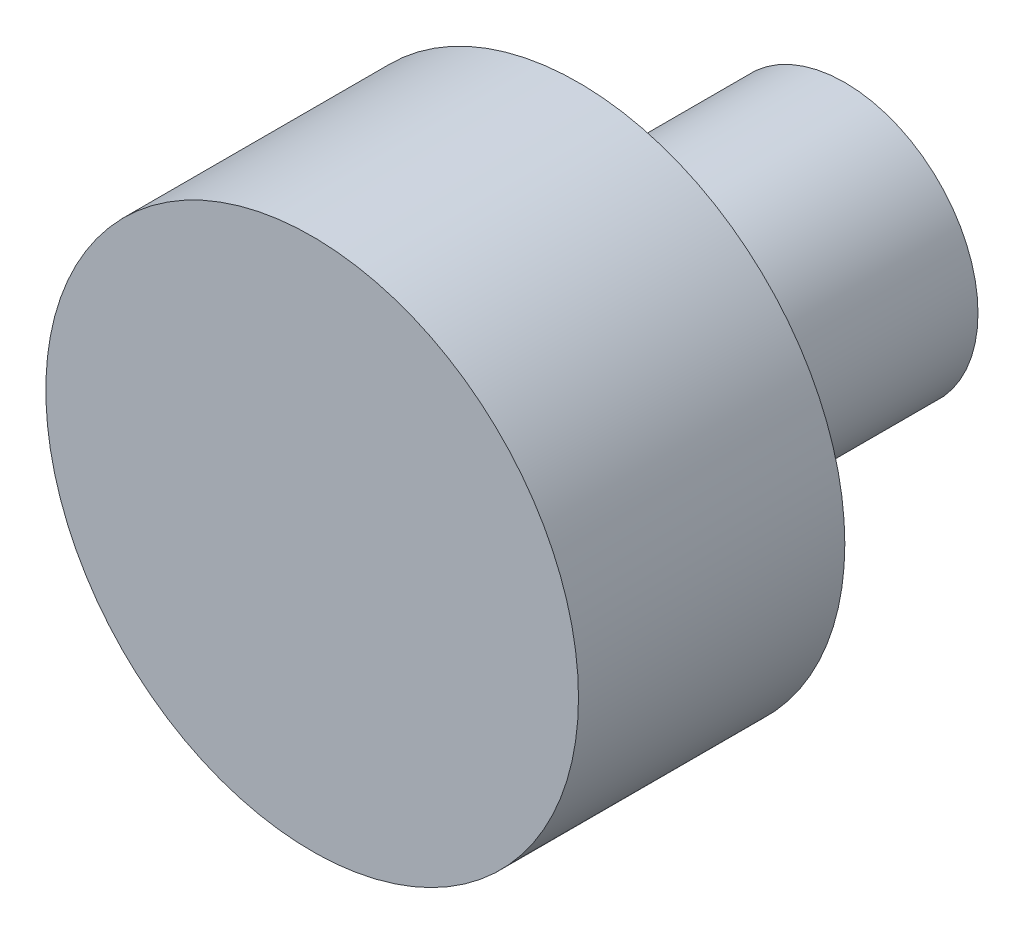
from build123d import *

# Parameters (mm, degrees)
SKETCH1_R           = 10
BOSS_EXTRUDE1_DEPTH = 20
SKETCH2_R           = 5
BOSS_EXTRUDE2_DEPTH = 10
SKETCH3_R           = 10
CUT_EXTRUDE1_DEPTH  = 10


with BuildPart() as part:
    # Sketch1 → Boss-Extrude1 (new body)
    with BuildSketch(Plane.XY):
        Circle(SKETCH1_R)
    extrude(amount=BOSS_EXTRUDE1_DEPTH)

    # Sketch2 → Boss-Extrude2 (add)
    with BuildSketch(Plane(origin=(0, 0, 0), x_dir=(-1, 0, 0), z_dir=(0, 0, -1))):
        Circle(SKETCH2_R)
    extrude(amount=BOSS_EXTRUDE2_DEPTH)

    # Sketch3 → Cut-Extrude1 (cut)
    with BuildSketch(Plane.XY.offset(20)):
        Circle(SKETCH3_R)
    extrude(amount=-CUT_EXTRUDE1_DEPTH, mode=Mode.SUBTRACT)


solid = part.part
